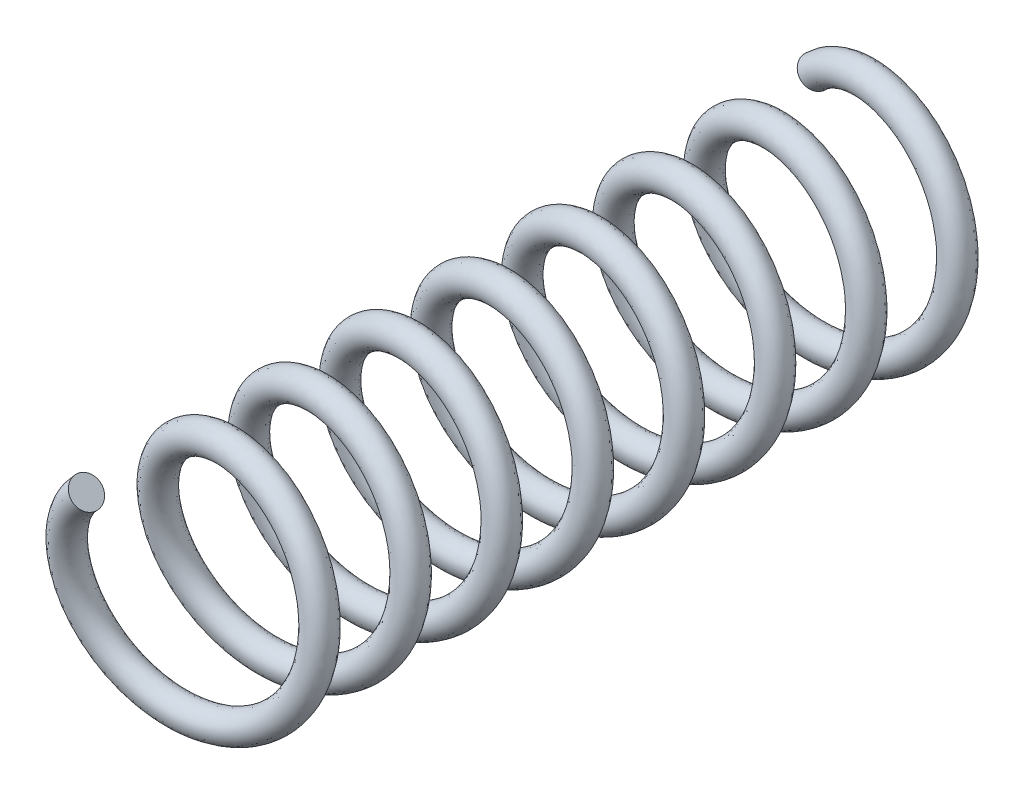
from build123d import *

# Parameters (mm, degrees)
BALAYAGE1_PITCH       = 4
BALAYAGE1_HEIGHT      = 32
BALAYAGE1_RADIUS      = 0.5
BALAYAGE1_START_ANGLE = 135
ESQUISSE3_R           = 0.65


with BuildPart() as part:
    # Balayage1: sweep along a helix
    with BuildLine() as balayage1_path:
        add(Helix(BALAYAGE1_PITCH, BALAYAGE1_HEIGHT, BALAYAGE1_RADIUS, center=(0, 0, 0), direction=(0, 0, 1), lefthand=True, mode=Mode.PRIVATE).rotate(Axis((0, 0, 0), (0, 0, 1)), BALAYAGE1_START_ANGLE))
    # Esquisse3 → Balayage1 (sweep)
    with BuildSketch(Plane(origin=(0, 0, 0), x_dir=(1, 0, 0), z_dir=(0, 1, 0))):
        with Locations((4.5, 0)):
            Circle(ESQUISSE3_R)
    sweep(path=balayage1_path.line, is_frenet=True)


solid = part.part
